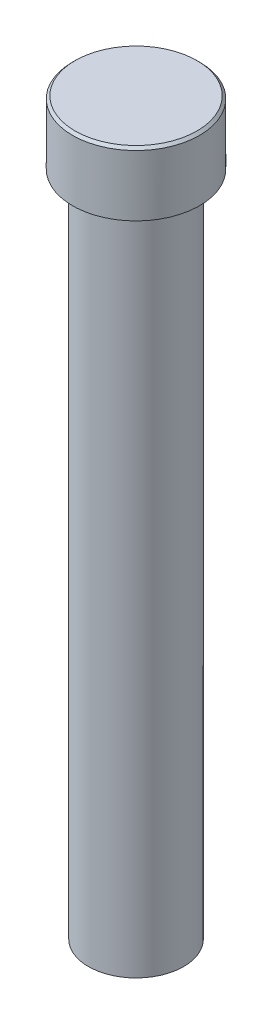
from build123d import *

# Parameters (mm, degrees)
CHAMFER1_SIZE = 0.254


with BuildPart() as part:
    # Sketch2 → Revolve1 (revolve)
    with BuildSketch(Plane.XY):
        Polygon((4.7625, 0), (4.7625, 66.675), (6.35, 66.675), (6.35, 73.025), (0, 73.025), (0, 0), align=None)
    revolve(axis=Axis((0, 0, 0), (0, 1, 0)))

    # Chamfer1
    chamfer1_edges = [part.edges().sort_by_distance(p)[0] for p in [
        (-6.35, 73.025, 0),
    ]]
    chamfer(chamfer1_edges, length=CHAMFER1_SIZE)


solid = part.part
